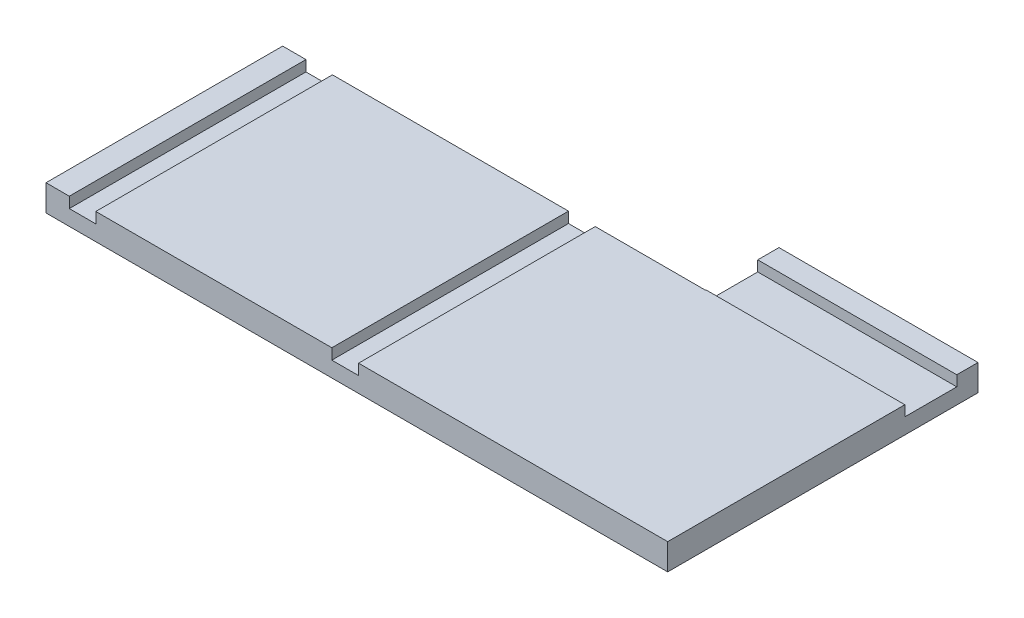
from build123d import *

# Parameters (mm, degrees)
BOSS_EXTRUDE1_DEPTH     = 5
SKETCH2_W               = 5.1
SKETCH2_H               = 2.05
CUT_EXTRUDE1_DEPTH      = 1
CUT_EXTRUDE1_DEPTH_BACK = 60.1838596
CUT_EXTRUDE2_REACH      = 116.127
SKETCH3_W               = 10
SKETCH3_H               = 2
SKETCH4_W               = 4.444636185
SKETCH4_H               = 5
BOSS_EXTRUDE2_DEPTH     = 45.135921
SKETCH5_W               = 0.1
SKETCH5_H               = 2
BOSS_EXTRUDE3_DEPTH     = 37.960973


with BuildPart() as part:
    # Sketch1 → Boss-Extrude1 (new body)
    with BuildSketch(Plane(origin=(0, 0, 0), x_dir=(1, 0, 0), z_dir=(0, 1, 0))):
        Polygon((0, 0), (114.126652136, 0), (114.126652136, 45.135921053), (114.126652136, 59.1838596), (76.165679632, 59.1838596), (76.165679632, 45.135921053), (0, 45.135921053), align=None)
    extrude(amount=BOSS_EXTRUDE1_DEPTH)

    # Sketch2 → Cut-Extrude1 (cut, two sides)
    with BuildSketch(Plane.XY) as cut_extrude1_sk:
        with Locations((2.5, 3.975)):
            Rectangle(SKETCH2_W, SKETCH2_H)
        with Locations((52.62, 3.975)):
            Rectangle(SKETCH2_W, SKETCH2_H)
    extrude(amount=CUT_EXTRUDE1_DEPTH, mode=Mode.SUBTRACT)
    extrude(cut_extrude1_sk.sketch, amount=-CUT_EXTRUDE1_DEPTH_BACK, mode=Mode.SUBTRACT)

    # Sketch3 → Cut-Extrude2 (cut, up to next)
    with BuildSketch(Plane(origin=(114.126652136, -2e-09, 0), x_dir=(0, 0, -1), z_dir=(1, 0, 0)), mode=Mode.PRIVATE) as cut_extrude2_sk1:
        with Locations((50.135921053, 4.000000002)):
            Rectangle(SKETCH3_W, SKETCH3_H)
    cut_extrude2_tool1 = extrude(cut_extrude2_sk1.sketch, amount=-CUT_EXTRUDE2_REACH, mode=Mode.PRIVATE) & part.part
    add(cut_extrude2_tool1.solids().sort_by_distance((114.126652, 4, -50.135921))[0], mode=Mode.SUBTRACT)

    # Sketch4 → Boss-Extrude2 (add)
    with BuildSketch(Plane.XY):
        with Locations((-2.222318093, 2.5)):
            Rectangle(SKETCH4_W, SKETCH4_H)
    extrude(amount=-BOSS_EXTRUDE2_DEPTH)

    # Sketch5 → Boss-Extrude3 (add)
    with BuildSketch(Plane(origin=(114.126652136, 0, 0), x_dir=(0, 0, -1), z_dir=(1, 0, 0))):
        with Locations((45.185921053, 4)):
            Rectangle(SKETCH5_W, SKETCH5_H)
    extrude(amount=-BOSS_EXTRUDE3_DEPTH)


solid = part.part
